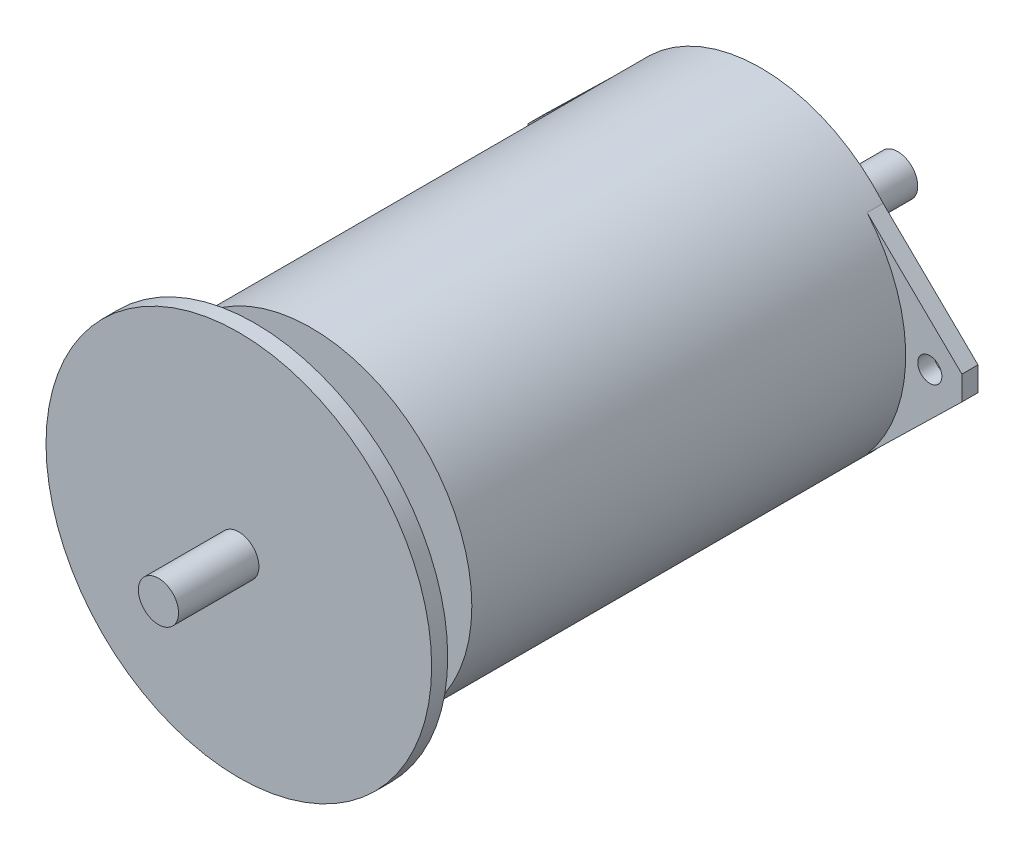
from build123d import *

# Parameters (mm, degrees)
SKETCH1_R                = 20
BOSS_EXTRUDE2_DEPTH      = 56
SKETCH1_4_R              = 1.5
BOSS_EXTRUDE3_DEPTH      = 2
SKETCH1_5_R              = 9
SKETCH1_5_R_2            = 2.5
BOSS_EXTRUDE4_DEPTH      = 4
BOSS_EXTRUDE6_DEPTH      = 65
BOSS_EXTRUDE6_DEPTH_BACK = 17
SKETCH1_7_R              = 2.5
SKETCH8_R                = 24
SKETCH8_R_2              = 2.5
BOSS_EXTRUDE9_DEPTH      = 2
SKETCH9_R                = 2.5
BOSS_EXTRUDE11_DEPTH     = 10


with BuildPart() as part:
    # Sketch1 → Boss-Extrude2 (new body)
    with BuildSketch(Plane.XY):
        with Locations((-44.212108768, 22.898771409)):
            Circle(SKETCH1_R)
    extrude(amount=BOSS_EXTRUDE2_DEPTH)

    # Sketch1_4 → Boss-Extrude3 (add)
    # profile 1 of 2: a face of its own
    with BuildSketch(Plane.XY):
        with BuildLine():
            Line((-71.211826981, 24.398484848), (-71.211826981, 21.399057969))
            Line((-71.211826981, 21.399057969), (-59.405868846, 9.893016732))
            ThreePointArc((-59.405868846, 9.893016732), (-64.212108768, 22.898771409), (-59.405868846, 35.904526085))
            Line((-59.405868846, 35.904526085), (-71.211826981, 24.398484848))
        make_face()
        with Locations((-67.212108768, 22.898771409)):
            Circle(SKETCH1_4_R, mode=Mode.SUBTRACT)
    # profile 2 of 2: a face of its own
    with BuildSketch(Plane.XY):
        with BuildLine():
            ThreePointArc((-29.018348691, 35.904526085), (-24.212108768, 22.898771409), (-29.018348691, 9.893016732))
            Line((-29.018348691, 9.893016732), (-17.212390555, 21.399057969))
            Line((-17.212390555, 21.399057969), (-17.212390555, 24.398484848))
            Line((-17.212390555, 24.398484848), (-29.018348691, 35.904526085))
        make_face()
        with Locations((-21.212108768, 22.898771409)):
            Circle(SKETCH1_4_R, mode=Mode.SUBTRACT)
    extrude(amount=BOSS_EXTRUDE3_DEPTH)

    # Sketch1_5 → Boss-Extrude4 (add)
    with BuildSketch(Plane.XY):
        with Locations((-44.212108768, 22.898771409)):
            Circle(SKETCH1_5_R)
        with Locations((-44.212108768, 22.898771409)):
            Circle(SKETCH1_5_R_2, mode=Mode.SUBTRACT)
    extrude(amount=-BOSS_EXTRUDE4_DEPTH)

    # Sketch1_7 → Boss-Extrude6 (add, two sides: drawn at the far end of the back side and taken through both)
    with BuildSketch(Plane.XY.offset(-BOSS_EXTRUDE6_DEPTH_BACK)):
        with Locations((-44.212108768, 22.898771409)):
            Circle(SKETCH1_7_R)
    extrude(amount=BOSS_EXTRUDE6_DEPTH + BOSS_EXTRUDE6_DEPTH_BACK)

    # Sketch8 → Boss-Extrude9 (add)
    with BuildSketch(Plane.XY.offset(65)):
        with Locations((-44.212108768, 22.898771409)):
            Circle(SKETCH8_R)
        with Locations((-44.212108768, 22.898771409)):
            Circle(SKETCH8_R_2, mode=Mode.SUBTRACT)
    extrude(amount=-BOSS_EXTRUDE9_DEPTH)

    # Sketch9 → Boss-Extrude11 (add)
    with BuildSketch(Plane.XY.offset(65)):
        with Locations((-44.212108768, 22.898771409)):
            Circle(SKETCH9_R)
    extrude(amount=BOSS_EXTRUDE11_DEPTH)


solid = part.part
